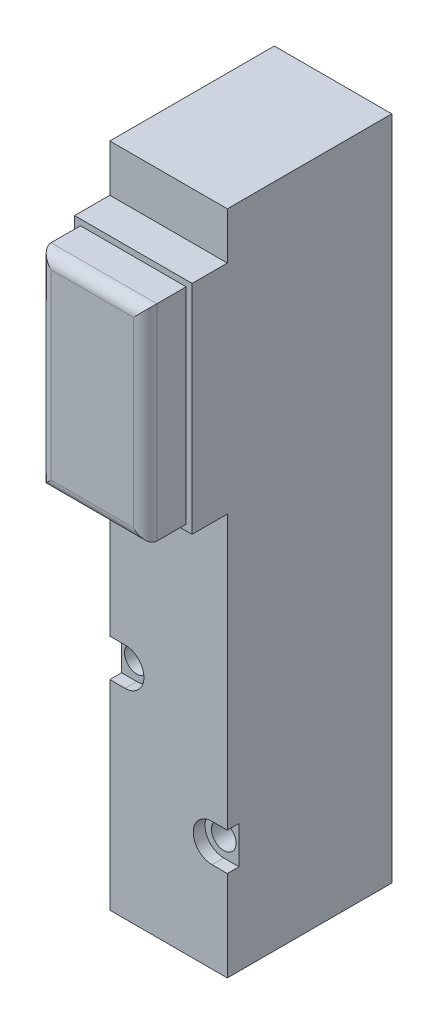
from build123d import *

# Parameters (mm, degrees)
SKETCH1_W                         = 10
SKETCH1_H                         = 14
EXTRUDE1_DEPTH                    = 56.7
SKETCH2_W                         = 10
SKETCH2_H                         = 18.498
EXTRUDE2_DEPTH                    = 3
M3X0_5_TAPPED_HOLE1_D             = 2.5
M3X0_5_TAPPED_HOLE1_DEPTH         = 7.5
M3X0_5_TAPPED_HOLE1_TIP           = 0.220408726
SKETCH5_R                         = 1.05
MANIFOLD_SCREWS_COUNTERBORE_DEPTH = 15
SKETCH6_R                         = 1.05
MOUNTING_HOLE_DEPTH               = 1
SKETCH7_W                         = 9
SKETCH7_H                         = 17.498
EXTRUDE3_DEPTH                    = 3.5
FILLET1_R                         = 1


with BuildPart() as part:
    # Sketch1 → Extrude1 (new body)
    with BuildSketch(Plane(origin=(0, 0, 0), x_dir=(1, 0, 0), z_dir=(0, 1, 0))):
        Rectangle(SKETCH1_W, SKETCH1_H)
    extrude(amount=-EXTRUDE1_DEPTH)

    # Sketch2 → Extrude2 (add)
    with BuildSketch(Plane.XY.offset(7)):
        with Locations((0, -13.249)):
            Rectangle(SKETCH2_W, SKETCH2_H)
    extrude(amount=EXTRUDE2_DEPTH)

    # M3x0.5 Tapped Hole1
    with Locations(Plane(origin=(0, -36.2, -7), x_dir=(-1, 0, 0), z_dir=(0, 0, -1))):
        with Locations((0, 0), (0, -6.4), (0, -12.8), (2, -9.6), (-2, -3.2)):
            Hole(M3X0_5_TAPPED_HOLE1_D / 2, depth=M3X0_5_TAPPED_HOLE1_DEPTH)
            with Locations((0, 0, -(M3X0_5_TAPPED_HOLE1_DEPTH + M3X0_5_TAPPED_HOLE1_TIP / 2))):  # 160° drill point
                Cone(0, M3X0_5_TAPPED_HOLE1_D / 2, M3X0_5_TAPPED_HOLE1_TIP, mode=Mode.SUBTRACT)

    # Sketch5 → Manifold Screws Counterbore (cut, through all)
    with BuildSketch(Plane.XY.offset(7)):
        with Locations((-3.7, -38.1)):
            Circle(SKETCH5_R)
        with Locations((3.7, -47.4)):
            Circle(SKETCH5_R)
    extrude(amount=-MANIFOLD_SCREWS_COUNTERBORE_DEPTH, mode=Mode.SUBTRACT)

    # Sketch6 → Mounting Hole (cut)
    with BuildSketch(Plane.XY.offset(7)):
        with BuildLine():
            ThreePointArc((-2.1, -38.1), (-2.56862915, -36.96862915), (-3.7, -36.5))
            ThreePointArc((-3.7, -36.5), (-4.4306228, -36.676556877), (-5, -37.167262095))
            Line((-5, -37.167262095), (-5, -39.032737905))
            ThreePointArc((-5, -39.032737905), (-4.4306228, -39.523443123), (-3.7, -39.7))
            ThreePointArc((-3.7, -39.7), (-2.56862915, -39.23137085), (-2.1, -38.1))
        make_face()
        with Locations((-3.7, -38.1)):
            Circle(SKETCH6_R, mode=Mode.SUBTRACT)
        with BuildLine():
            Line((5, -48.332737905), (5, -46.467262095))
            ThreePointArc((5, -46.467262095), (4.4306228, -45.976556877), (3.7, -45.8))
            ThreePointArc((3.7, -45.8), (2.1, -47.4), (3.7, -49))
            ThreePointArc((3.7, -49), (4.4306228, -48.823443123), (5, -48.332737905))
        make_face()
        with Locations((3.7, -47.4)):
            Circle(SKETCH6_R, mode=Mode.SUBTRACT)
        with BuildLine():
            Line((5, -46.467262095), (5, -45.8))
            Line((5, -45.8), (3.7, -45.8))
            ThreePointArc((3.7, -45.8), (4.4306228, -45.976556877), (5, -46.467262095))
        make_face()
        with BuildLine():
            Line((5, -49), (5, -48.332737905))
            ThreePointArc((5, -48.332737905), (4.4306228, -48.823443123), (3.7, -49))
            Line((3.7, -49), (5, -49))
        make_face()
        with BuildLine():
            ThreePointArc((-5, -37.167262095), (-4.4306228, -36.676556877), (-3.7, -36.5))
            Line((-3.7, -36.5), (-5, -36.5))
            Line((-5, -36.5), (-5, -37.167262095))
        make_face()
        with BuildLine():
            Line((-5, -39.7), (-3.7, -39.7))
            ThreePointArc((-3.7, -39.7), (-4.4306228, -39.523443123), (-5, -39.032737905))
            Line((-5, -39.032737905), (-5, -39.7))
        make_face()
    extrude(amount=-MOUNTING_HOLE_DEPTH, mode=Mode.SUBTRACT)

    # Sketch7 → Extrude3 (add)
    with BuildSketch(Plane.XY.offset(10)):
        with Locations((0, -13.249)):
            Rectangle(SKETCH7_W, SKETCH7_H)
    extrude(amount=EXTRUDE3_DEPTH)

    # Fillet1
    fillet1_edges = [part.edges().sort_by_distance(p)[0] for p in [
        (0, -4.5, 13.5),
        (-4.5, -13.249, 13.5),
        (0, -21.998, 13.5),
        (4.5, -13.249, 13.5),
    ]]
    fillet(fillet1_edges, radius=FILLET1_R)


solid = part.part
